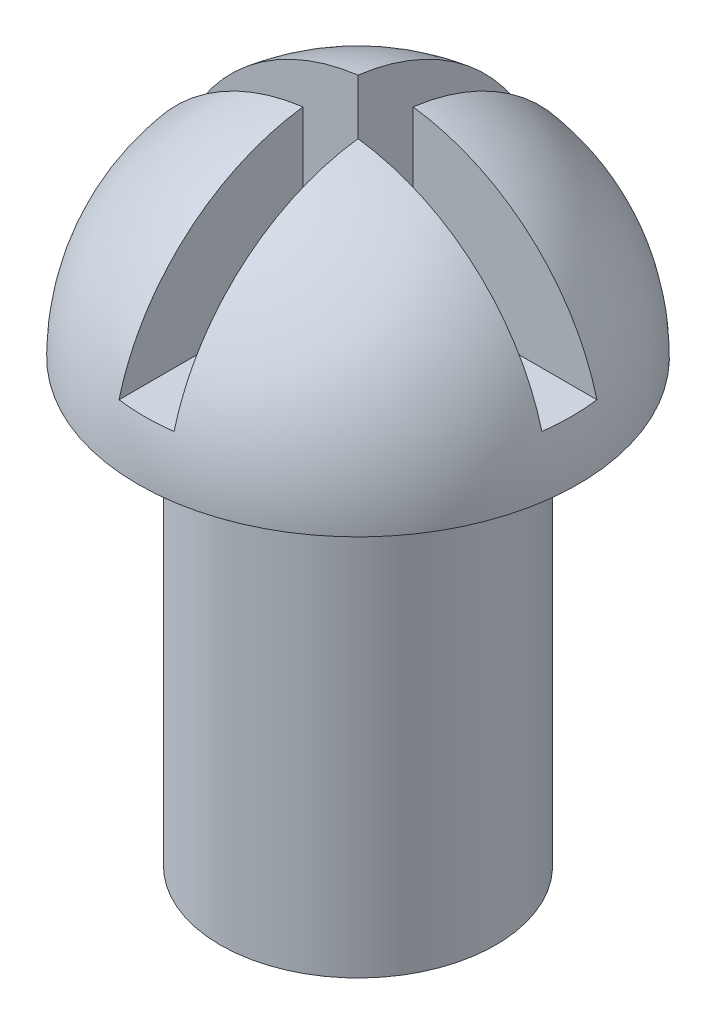
from build123d import *

# Parameters (mm, degrees)
SKETCH1_R           = 2.5
BOSS_EXTRUDE1_DEPTH = 8
REVOLVE1_ANGLE      = 180
CUT_EXTRUDE1_DEPTH  = 3


with BuildPart() as part:
    # Sketch1 → Boss-Extrude1 (new body)
    with BuildSketch(Plane(origin=(0, 0, 0), x_dir=(1, 0, 0), z_dir=(0, 1, 0))):
        Circle(SKETCH1_R)
    extrude(amount=BOSS_EXTRUDE1_DEPTH)

    # Sketch2 → Revolve1 (revolve)
    with BuildSketch(Plane(origin=(0, 8, 0), x_dir=(1, 0, 0), z_dir=(0, 1, 0))):
        with BuildLine():
            Line((0, 4), (0, -4))
            ThreePointArc((0, -4), (4, 0), (0, 4))
        make_face()
    revolve(axis=Axis((0, 8, -4), (0, 0, 1)), revolution_arc=REVOLVE1_ANGLE)

    # Sketch3 → Cut-Extrude1 (cut)
    with BuildSketch(Plane(origin=(0, 9, 0), x_dir=(1, 0, 0), z_dir=(0, 1, 0))):
        Polygon((0.5, 0.5), (5.630024771, 0.5), (5.630024771, -0.5), (0.5, -0.5), (0.5, -4.833323152), (-0.5, -4.833323152), (-0.5, -0.5), (-4.833323152, -0.5), (-4.833323152, 0.5), (-0.5, 0.5), (-0.5, 4.673982829), (0.5, 4.673982829), align=None)
    extrude(amount=CUT_EXTRUDE1_DEPTH, mode=Mode.SUBTRACT)


solid = part.part
